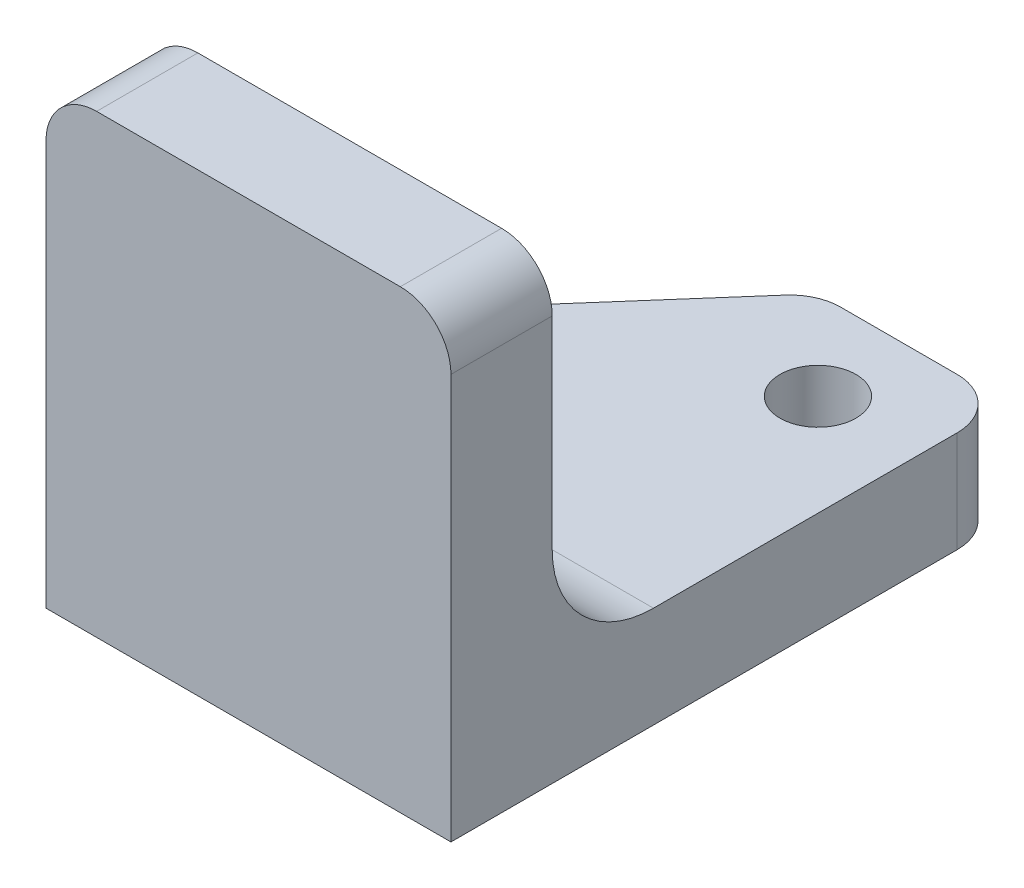
from build123d import *

# Parameters (mm, degrees)
BOSS_EXTRUDE1_DEPTH          = 4
SKETCH2_W                    = 16
SKETCH2_H                    = 18
BOSS_EXTRUDE2_DEPTH          = 4
FILLET1_R                    = 4
F_3_0_3_DIAMETER_HOLE1_D     = 3
F_3_0_3_DIAMETER_HOLE1_DEPTH = 30
F_3_0_3_DIAMETER_HOLE1_TIP   = 0.901290929
CUT_EXTRUDE1_DEPTH           = 10
FILLET2_R                    = 2


with BuildPart() as part:
    # Sketch1 → Boss-Extrude1 (new body)
    with BuildSketch(Plane.XY):
        with BuildLine():
            Line((0, 0), (0, 16))
            ThreePointArc((0, 16), (0.585786438, 17.414213562), (2, 18))
            Line((2, 18), (14, 18))
            ThreePointArc((14, 18), (15.414213562, 17.414213562), (16, 16))
            Line((16, 16), (16, 0))
            Line((16, 0), (0, 0))
        make_face()
    extrude(amount=BOSS_EXTRUDE1_DEPTH)

    # Sketch2 → Boss-Extrude2 (add)
    with BuildSketch(Plane(origin=(0, 0, 0), x_dir=(1, 0, 0), z_dir=(0, 1, 0))):
        with Locations((8, 9)):
            Rectangle(SKETCH2_W, SKETCH2_H)
    extrude(amount=BOSS_EXTRUDE2_DEPTH)

    # Fillet1
    fillet1_edges = [part.edges().sort_by_distance(p)[0] for p in [
        (8, 4, 0),
    ]]
    fillet(fillet1_edges, radius=FILLET1_R)

    # Ø3.0 (3) Diameter Hole1
    with Locations(Plane(origin=(939.624698197, 4, -711.338031018), x_dir=(-0.041819335, 0, -0.999125189), z_dir=(0, 1, 0))):
        with Locations((-665.06790374, 963.218082486), (-657.435781521, 955.954504856)):
            Hole(F_3_0_3_DIAMETER_HOLE1_D / 2, depth=F_3_0_3_DIAMETER_HOLE1_DEPTH)
            with Locations((0, 0, -(F_3_0_3_DIAMETER_HOLE1_DEPTH + F_3_0_3_DIAMETER_HOLE1_TIP / 2))):  # 118° drill point
                Cone(0, F_3_0_3_DIAMETER_HOLE1_D / 2, F_3_0_3_DIAMETER_HOLE1_TIP, mode=Mode.SUBTRACT)

    # Sketch6 → Cut-Extrude1 (cut)
    with BuildSketch(Plane(origin=(0, 4, 0), x_dir=(1, 0, 0), z_dir=(0, 1, 0))):
        Polygon((8.487460621, 18), (0, 8.300045005), (0, 18), align=None)
    extrude(amount=-CUT_EXTRUDE1_DEPTH, mode=Mode.SUBTRACT)

    # Fillet2
    fillet2_edges = [part.edges().sort_by_distance(p)[0] for p in [
        (16, 2, -18),
        (0, 2, -8.300045005),
        (8.487460621, 2, -18),
    ]]
    fillet(fillet2_edges, radius=FILLET2_R)


solid = part.part
